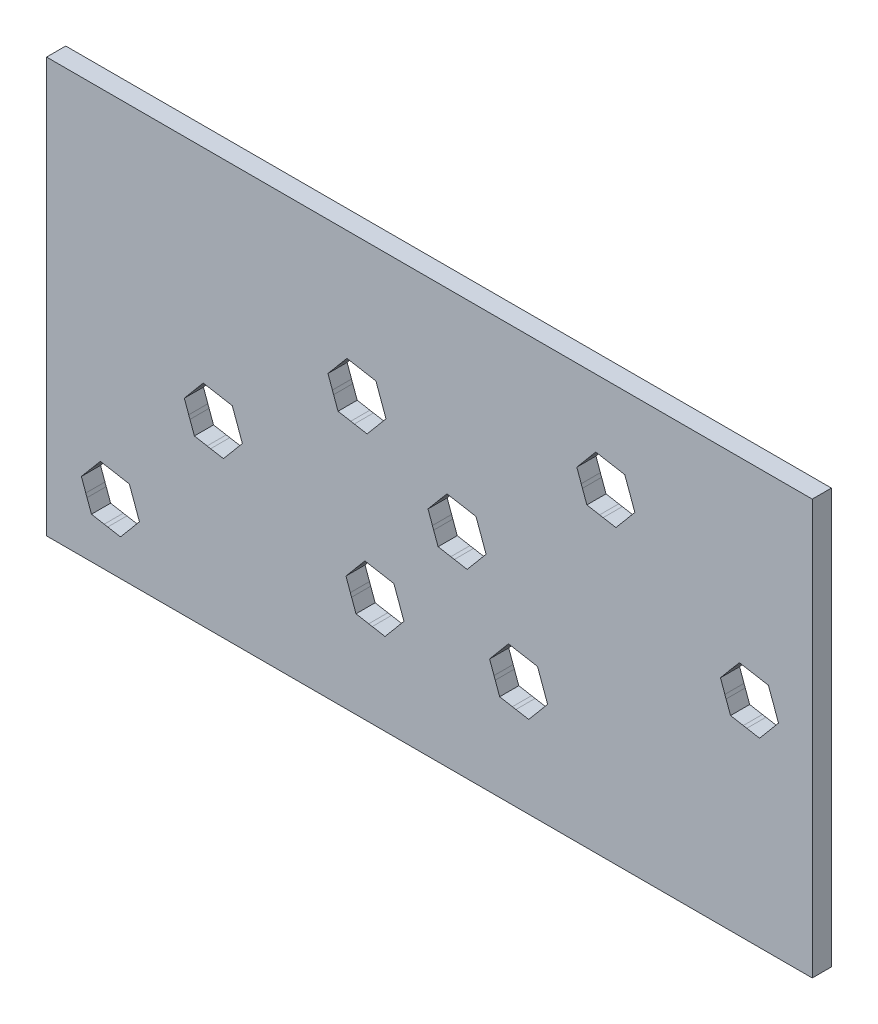
from build123d import *

# Parameters (mm, degrees)
SKIZZE1_W                       = 120
SKIZZE1_H                       = 65
AUFSATZ_LINEAR_AUSTRAGEN1_DEPTH = 3
SECHSKANT_DEPTH                 = 4
SKIZZE3_R                       = 4.01
ZYLINDERBOHRUNG_DEPTH           = 4


with BuildPart() as part:
    # Skizze1 → Aufsatz-Linear austragen1 (new body)
    with BuildSketch(Plane.XY):
        with Locations((60, 32.5)):
            Rectangle(SKIZZE1_W, SKIZZE1_H)
    extrude(amount=AUFSATZ_LINEAR_AUSTRAGEN1_DEPTH)

    # Skizze2 → Sechskant (cut, through all)
    with BuildSketch(Plane.XY.offset(3)):
        Polygon((12.968908796, 13.538207724), (8.420276625, 14.340254301), (5.45136783, 10.802046577), (7.031091204, 6.461792276), (11.579723375, 5.659745699), (14.54863217, 9.197953423), align=None)
    sechskant = extrude(amount=-SECHSKANT_DEPTH, mode=Mode.SUBTRACT)

    # Skizze3 → Zylinderbohrung (cut, through all)
    with BuildSketch(Plane.XY.offset(3)):
        with Locations((10, 10)):
            Circle(SKIZZE3_R)
    zylinderbohrung = extrude(amount=-ZYLINDERBOHRUNG_DEPTH, mode=Mode.SUBTRACT)

    # Skizzen-Muster1: Sechskant, Zylinderbohrung at 7 more places
    with Locations((16.131362, 18.688541, 0), (38.646381, 33.298896, 0), (63.975777, 7.214865, 0), (77.645609, 40.086657, 0), (100.160628, 22.754647, 0), (41.460758, 7.214865, 0), (54.326483, 22.754647, 0)):
        add(sechskant, mode=Mode.SUBTRACT)
        add(zylinderbohrung, mode=Mode.SUBTRACT)


solid = part.part
